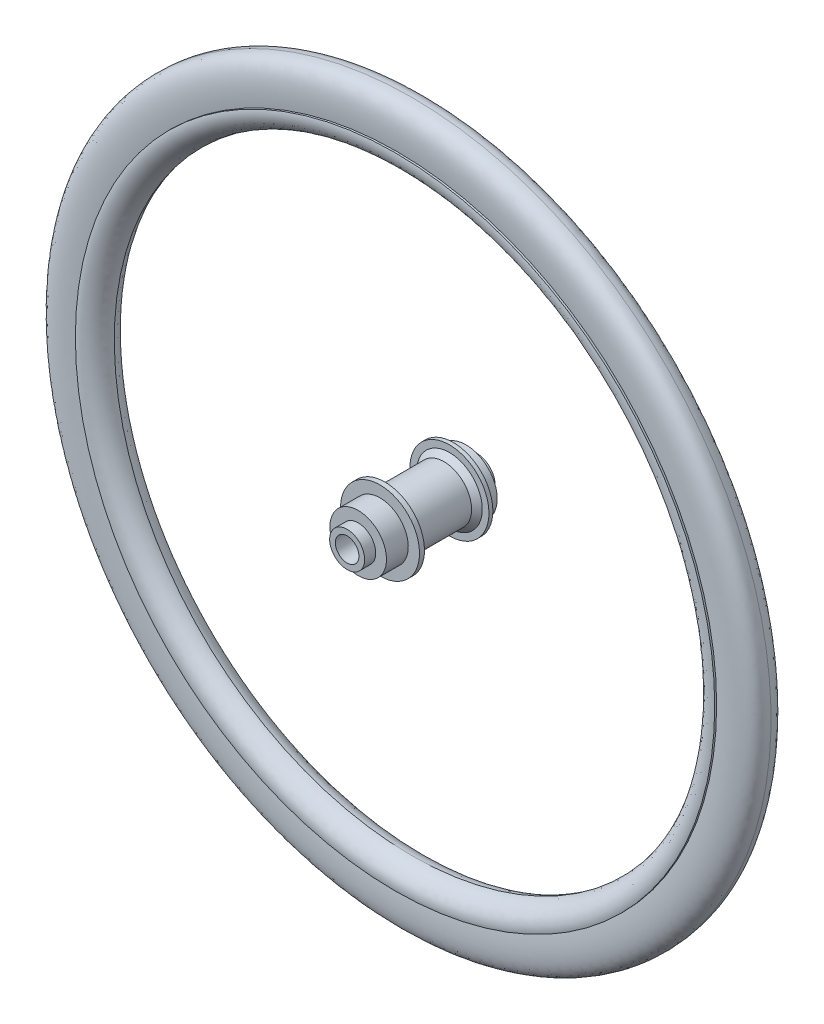
from build123d import *


with BuildPart() as part:
    # Sketch3 → Revolve7 (revolve)
    with BuildSketch(Plane(origin=(0, 0, 0), x_dir=(0, 0, -1), z_dir=(1, 0, 0))):
        with BuildLine():
            Line((12.5, 269.8), (-12.5, 269.8))
            add(Edge.make_bspline(
                [(0, 304.8), (-3.105781233, 304.713103163), (-4.786987293, 304.290095567), (-6.534544097, 303.461281857), (-16.72314658, 298.659601339), (-12.5, 269.8)],
                knots=[0, 0, 0, 0, 0.441572013, 0.519847255, 1, 1, 1, 1], degree=3))
            add(Edge.make_bspline(
                [(0, 304.8), (3.105781233, 304.713103163), (4.786987293, 304.290095567), (6.534544097, 303.461281857), (16.72314658, 298.659601339), (12.5, 269.8)],
                knots=[0, 0, 0, 0, 0.441572013, 0.519847255, 1, 1, 1, 1], degree=3))
        make_face()
    revolve(axis=Axis((0, 0, 127), (0, 0, -1)))

    # Sketch6 → Revolve8 (revolve)
    with BuildSketch(Plane(origin=(0, 0, 0), x_dir=(0, 0, -1), z_dir=(1, 0, 0))):
        with BuildLine():
            Line((-14.331840629, 271.349373607), (14.331840629, 271.349373607))
            add(Edge.make_bspline(
                [(14.331840629, 271.349373607), (16.551853232, 262.359742007), (8.764143835, 253.337072556), (0, 252.628130209)],
                knots=[0, 0, 0, 0, 1, 1, 1, 1], degree=3))
            add(Edge.make_bspline(
                [(-14.331840629, 271.349373607), (-16.551853232, 262.359742007), (-8.764143835, 253.337072556), (0, 252.628130209)],
                knots=[0, 0, 0, 0, 1, 1, 1, 1], degree=3))
        make_face()
    revolve(axis=Axis((0, 0, 127), (0, 0, -1)))


with BuildPart() as body_2:
    # Sketch7 → Revolve9 (revolve)
    with BuildSketch(Plane(origin=(0, 0, 0), x_dir=(0, 0, -1), z_dir=(1, 0, 0))):
        Polygon((-55, 10), (-55, 14.848062252), (-45.598919058, 14.848062252), (-45.598919058, 24.001020337), (-27.110679023, 24.001020337), (-27.110679023, 33.528), (-22.889320977, 33.528), (-22.889320977, 27.859129332), (-18.611803116, 23.417091554), (27.224053079, 23.417091554), (31.836938465, 27.859129332), (31.836938465, 33.528), (35.163061535, 33.528), (35.163061535, 26.482460588), (45.902896762, 26.482460588), (45.902896762, 15.704316331), (55, 15.704316331), (55, 10), align=None)
    revolve(axis=Axis((0, 0, 127), (0, 0, -1)))


solid = Compound([part.part, body_2.part])
